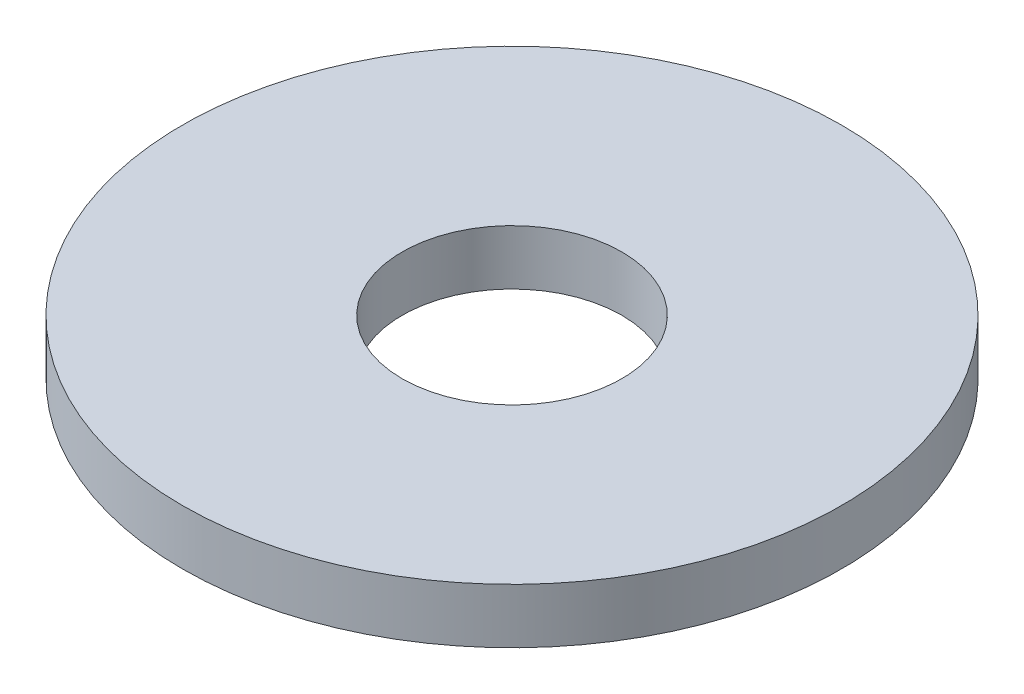
from build123d import *

# Parameters (mm, degrees)
SZKIC1_W = 20
SZKIC1_H = 5


with BuildPart() as part:
    # Szkic1 → Obrót1 (revolve)
    with BuildSketch(Plane.XY):
        with Locations((-20, 9.972196922)):
            Rectangle(SZKIC1_W, SZKIC1_H)
    revolve(axis=Axis((0, 0, 0), (0, 1, 0)))


solid = part.part
